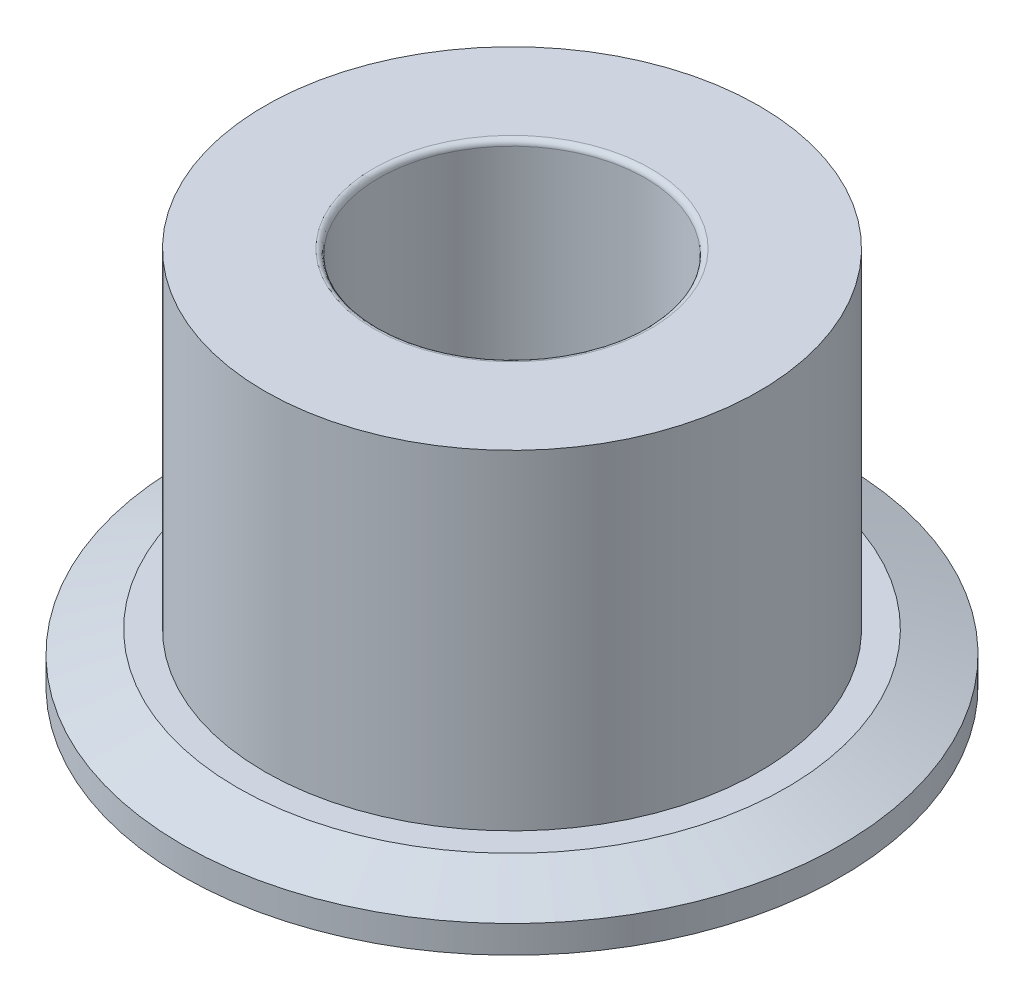
from build123d import *

# Parameters (mm, degrees)
SKETCH_1_R      = 6
SKETCH_1_R_2    = 2.425
EXTRUDE_1_DEPTH = 0.9
SKETCH_2_R      = 4.5
SKETCH_2_R_2    = 2.425
EXTRUDE_2_DEPTH = 6
FILLET_1_R      = 0.1
CHAMFER_1_SIZE  = 0.4
CHAMFER_1_SIZE2 = 1


with BuildPart() as part:
    # 草图1 → 凸台-拉伸1 (new body)
    with BuildSketch(Plane(origin=(0, 0, 0), x_dir=(1, 0, 0), z_dir=(0, 1, 0))):
        Circle(SKETCH_1_R)
        Circle(SKETCH_1_R_2, mode=Mode.SUBTRACT)
    extrude(amount=EXTRUDE_1_DEPTH)

    # 草图2 → 凸台-拉伸2 (add)
    with BuildSketch(Plane(origin=(0, 0.9, 0), x_dir=(1, 0, 0), z_dir=(0, 1, 0))):
        Circle(SKETCH_2_R)
        Circle(SKETCH_2_R_2, mode=Mode.SUBTRACT)
    extrude(amount=EXTRUDE_2_DEPTH)

    # 圆角1
    fillet_1_edges = [part.edges().sort_by_distance(p)[0] for p in [
        (-2.425, 6.9, 0),
    ]]
    fillet(fillet_1_edges, radius=FILLET_1_R)

    # 倒角1
    chamfer_1_edges = [part.edges().sort_by_distance(p)[0] for p in [
        (-6, 0.9, 0),
    ]]
    chamfer_1_side = [part.faces().sort_by_distance(p)[0] for p in [
        (-6, 0.45, 0),
    ]]
    chamfer(chamfer_1_edges, length=CHAMFER_1_SIZE, length2=CHAMFER_1_SIZE2, reference=chamfer_1_side[0])


solid = part.part
